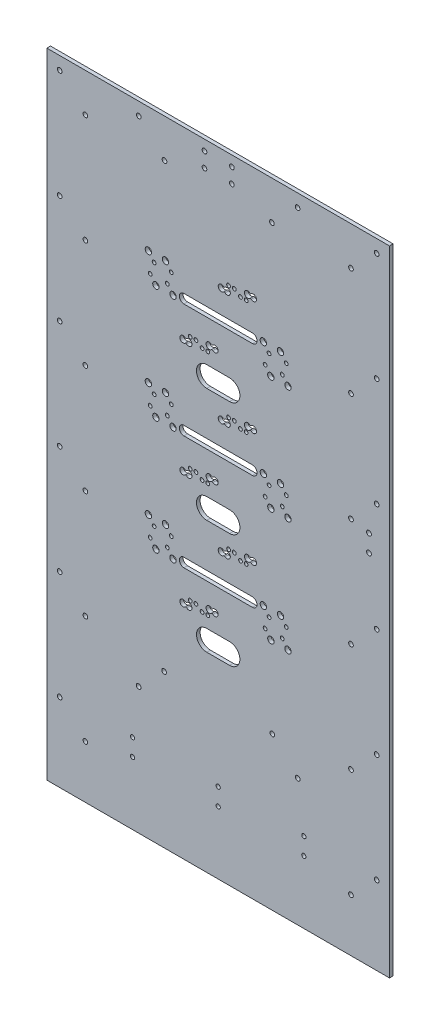
from build123d import *

# Parameters (mm, degrees)
SKETCH1_W           = 300
SKETCH1_H           = 555
BOSS_EXTRUDE1_DEPTH = 3.175
CUT_EXTRUDE1_DEPTH  = 10
SKETCH6_R           = 2.05
CUT_EXTRUDE5_DEPTH  = 51
SKETCH8_R           = 2.1
CUT_EXTRUDE7_DEPTH  = 67
SKETCH9_R           = 2.05
CUT_EXTRUDE8_DEPTH  = 10
SKETCH10_R          = 1.651
SKETCH10_R_2        = 2.794
CUT_EXTRUDE9_DEPTH  = 10
SKETCH12_R          = 1.85
CUT_EXTRUDE10_DEPTH = 10
CUT_EXTRUDE11_DEPTH = 29.1


with BuildPart() as part:
    # Sketch1 → Boss-Extrude1 (new body)
    with BuildSketch(Plane.XY):
        with Locations((-15.986837609, 112.215563673)):
            Rectangle(SKETCH1_W, SKETCH1_H)
    extrude(amount=BOSS_EXTRUDE1_DEPTH)

    # Sketch4 → Cut-Extrude1 (cut)
    with BuildSketch(Plane.XY.offset(3.175)):
        with BuildLine():
            Line((-45.986837609, 263.715563673), (14.013162391, 263.715563673))
            ThreePointArc((14.013162391, 263.715563673), (18.013162391, 259.715563673), (14.013162391, 255.715563673))
            Line((14.013162391, 255.715563673), (-45.986837609, 255.715563673))
            ThreePointArc((-45.986837609, 255.715563673), (-49.986837609, 259.715563673), (-45.986837609, 263.715563673))
        make_face()
        with BuildLine():
            Line((-45.986837609, 163.715563673), (14.013162391, 163.715563673))
            ThreePointArc((14.013162391, 163.715563673), (18.013162391, 159.715563673), (14.013162391, 155.715563673))
            Line((14.013162391, 155.715563673), (-45.986837609, 155.715563673))
            ThreePointArc((-45.986837609, 155.715563673), (-49.986837609, 159.715563673), (-45.986837609, 163.715563673))
        make_face()
        with BuildLine():
            Line((-45.986837609, 63.715563673), (14.013162391, 63.715563673))
            ThreePointArc((14.013162391, 63.715563673), (18.013162391, 59.715563673), (14.013162391, 55.715563673))
            Line((14.013162391, 55.715563673), (-45.986837609, 55.715563673))
            ThreePointArc((-45.986837609, 55.715563673), (-49.986837609, 59.715563673), (-45.986837609, 63.715563673))
        make_face()
    extrude(amount=-CUT_EXTRUDE1_DEPTH, mode=Mode.SUBTRACT)

    # Sketch6 → Cut-Extrude5 (cut)
    with BuildSketch(Plane(origin=(0, 0, 0), x_dir=(-1, 0, 0), z_dir=(0, 0, -1))):
        with Locations((3.986837609, 380.715563673)):
            Circle(SKETCH6_R)
        with Locations((27.986837609, 380.715563673)):
            Circle(SKETCH6_R)
        with Locations((27.986837609, 367.715563673)):
            Circle(SKETCH6_R)
        with Locations((3.986837609, 367.715563673)):
            Circle(SKETCH6_R)
    extrude(amount=-CUT_EXTRUDE5_DEPTH, mode=Mode.SUBTRACT)

    # Sketch8 → Cut-Extrude7 (cut)
    with BuildSketch(Plane(origin=(0, 0, 0), x_dir=(-1, 0, 0), z_dir=(0, 0, -1))):
        with Locations((-116.013162391, 162.980338842)):
            Circle(SKETCH8_R)
        with Locations((-116.013162391, 147.980338842)):
            Circle(SKETCH8_R)
    extrude(amount=-CUT_EXTRUDE7_DEPTH, mode=Mode.SUBTRACT)

    # Sketch9 → Cut-Extrude8 (cut)
    with BuildSketch(Plane(origin=(0, 0, 0), x_dir=(-1, 0, 0), z_dir=(0, 0, -1))):
        with Locations((-122.763162391, 378.465563673)):
            Circle(SKETCH9_R)
        with Locations((-100.263162391, 355.965563673)):
            Circle(SKETCH9_R)
        with Locations((-53.536763897, 378.465563673)):
            Circle(SKETCH9_R)
        with Locations((-31.036763897, 355.965563673)):
            Circle(SKETCH9_R)
        with Locations((-122.763162391, 283.465563673)):
            Circle(SKETCH9_R)
        with Locations((-100.263162391, 260.965563673)):
            Circle(SKETCH9_R)
        with Locations((-122.763162391, 188.465563673)):
            Circle(SKETCH9_R)
        with Locations((-100.263162391, 165.965563673)):
            Circle(SKETCH9_R)
        with Locations((-122.763162391, 93.465563673)):
            Circle(SKETCH9_R)
        with Locations((-100.263162391, 70.965563673)):
            Circle(SKETCH9_R)
        with Locations((-122.763162391, -1.534436327)):
            Circle(SKETCH9_R)
        with Locations((-100.263162391, -24.034436327)):
            Circle(SKETCH9_R)
        with Locations((-122.763162391, -96.534436327)):
            Circle(SKETCH9_R)
        with Locations((-100.263162391, -119.034436327)):
            Circle(SKETCH9_R)
        with Locations((-122.763162391, -191.534436327)):
            Circle(SKETCH9_R)
        with Locations((-100.263162391, -214.034436327)):
            Circle(SKETCH9_R)
        with Locations((-53.648179996, -54.034436327)):
            Circle(SKETCH9_R)
        with Locations((-31.371012194, -31.534436327)):
            Circle(SKETCH9_R)
        with Locations((63.344687413, -31.534436327)):
            Circle(SKETCH9_R)
        with Locations((85.621855215, -54.034436327)):
            Circle(SKETCH9_R)
        with Locations((132.236837609, -214.034436327)):
            Circle(SKETCH9_R)
        with Locations((154.736837609, -191.534436327)):
            Circle(SKETCH9_R)
        with Locations((132.236837609, -119.034436327)):
            Circle(SKETCH9_R)
        with Locations((154.736837609, -96.534436327)):
            Circle(SKETCH9_R)
        with Locations((132.236837609, -24.034436327)):
            Circle(SKETCH9_R)
        with Locations((154.736837609, -1.534436327)):
            Circle(SKETCH9_R)
        with Locations((132.236837609, 70.965563673)):
            Circle(SKETCH9_R)
        with Locations((154.736837609, 93.465563673)):
            Circle(SKETCH9_R)
        with Locations((132.236837609, 165.965563673)):
            Circle(SKETCH9_R)
        with Locations((154.736837609, 188.465563673)):
            Circle(SKETCH9_R)
        with Locations((132.236837609, 260.965563673)):
            Circle(SKETCH9_R)
        with Locations((154.736837609, 283.465563673)):
            Circle(SKETCH9_R)
        with Locations((63.010439116, 355.965563673)):
            Circle(SKETCH9_R)
        with Locations((85.510439116, 378.465563673)):
            Circle(SKETCH9_R)
        with Locations((132.236837609, 355.965563673)):
            Circle(SKETCH9_R)
        with Locations((154.736837609, 378.465563673)):
            Circle(SKETCH9_R)
    extrude(amount=-CUT_EXTRUDE8_DEPTH, mode=Mode.SUBTRACT)

    # Sketch10 → Cut-Extrude9 (cut)
    with BuildSketch(Plane(origin=(0, 0, 0), x_dir=(-1, 0, 0), z_dir=(0, 0, -1))):
        with Locations((35.464045315, 33.621645855)):
            Circle(SKETCH10_R)
        with Locations((25.105079811, 30.160155179)):
            Circle(SKETCH10_R)
        with Locations((-30.126255431, 38.933594969)):
            Circle(SKETCH10_R_2)
        with Locations((-23.543411665, 61.884184155)):
            Circle(SKETCH10_R_2)
        with Locations((-25.10242235, 45.229963762)):
            Circle(SKETCH10_R)
        with Locations((-28.567244746, 55.587815362)):
            Circle(SKETCH10_R)
        with Locations((-45.126255431, 38.933594969)):
            Circle(SKETCH10_R_2)
        with Locations((-38.543411665, 61.884184155)):
            Circle(SKETCH10_R_2)
        with Locations((-40.10242235, 45.229963762)):
            Circle(SKETCH10_R)
        with Locations((-43.567244746, 55.587815362)):
            Circle(SKETCH10_R)
        with Locations((40.464045315, 33.621645855)):
            Circle(SKETCH10_R)
        with Locations((30.105079811, 30.160155179)):
            Circle(SKETCH10_R)
        with Locations((55.517086884, 57.54692847)):
            Circle(SKETCH10_R_2)
        with Locations((70.517086884, 57.54692847)):
            Circle(SKETCH10_R_2)
        with Locations((75.540919965, 63.843297263)):
            Circle(SKETCH10_R)
        with Locations((60.540919965, 63.843297263)):
            Circle(SKETCH10_R)
        with Locations((-3.490370096, 85.80947413)):
            Circle(SKETCH10_R)
        with Locations((6.868595408, 89.270964805)):
            Circle(SKETCH10_R)
        with Locations((62.09993065, 80.497517656)):
            Circle(SKETCH10_R_2)
        with Locations((57.076097569, 74.201148863)):
            Circle(SKETCH10_R)
        with Locations((77.09993065, 80.497517656)):
            Circle(SKETCH10_R_2)
        with Locations((72.076097569, 74.201148863)):
            Circle(SKETCH10_R)
        with Locations((-8.490370096, 85.80947413)):
            Circle(SKETCH10_R)
        with Locations((1.868595408, 89.270964805)):
            Circle(SKETCH10_R)
        with Locations((35.464045315, 133.621645855)):
            Circle(SKETCH10_R)
        with Locations((25.105079811, 130.160155179)):
            Circle(SKETCH10_R)
        with Locations((-30.126255431, 138.933594969)):
            Circle(SKETCH10_R_2)
        with Locations((-23.543411665, 161.884184155)):
            Circle(SKETCH10_R_2)
        with Locations((-25.10242235, 145.229963762)):
            Circle(SKETCH10_R)
        with Locations((-28.567244746, 155.587815362)):
            Circle(SKETCH10_R)
        with Locations((-45.126255431, 138.933594969)):
            Circle(SKETCH10_R_2)
        with Locations((-38.543411665, 161.884184155)):
            Circle(SKETCH10_R_2)
        with Locations((-40.10242235, 145.229963762)):
            Circle(SKETCH10_R)
        with Locations((-43.567244746, 155.587815362)):
            Circle(SKETCH10_R)
        with Locations((40.464045315, 133.621645855)):
            Circle(SKETCH10_R)
        with Locations((30.105079811, 130.160155179)):
            Circle(SKETCH10_R)
        with Locations((55.517086884, 157.54692847)):
            Circle(SKETCH10_R_2)
        with Locations((70.517086884, 157.54692847)):
            Circle(SKETCH10_R_2)
        with Locations((75.540919965, 163.843297263)):
            Circle(SKETCH10_R)
        with Locations((60.540919965, 163.843297263)):
            Circle(SKETCH10_R)
        with Locations((-3.490370096, 185.80947413)):
            Circle(SKETCH10_R)
        with Locations((6.868595408, 189.270964805)):
            Circle(SKETCH10_R)
        with Locations((62.09993065, 180.497517656)):
            Circle(SKETCH10_R_2)
        with Locations((57.076097569, 174.201148863)):
            Circle(SKETCH10_R)
        with Locations((77.09993065, 180.497517656)):
            Circle(SKETCH10_R_2)
        with Locations((72.076097569, 174.201148863)):
            Circle(SKETCH10_R)
        with Locations((-8.490370096, 185.80947413)):
            Circle(SKETCH10_R)
        with Locations((1.868595408, 189.270964805)):
            Circle(SKETCH10_R)
        with Locations((35.464045315, 233.621645855)):
            Circle(SKETCH10_R)
        with Locations((25.105079811, 230.160155179)):
            Circle(SKETCH10_R)
        with Locations((-30.126255431, 238.933594969)):
            Circle(SKETCH10_R_2)
        with Locations((-23.543411665, 261.884184155)):
            Circle(SKETCH10_R_2)
        with Locations((-25.10242235, 245.229963762)):
            Circle(SKETCH10_R)
        with Locations((-28.567244746, 255.587815362)):
            Circle(SKETCH10_R)
        with Locations((-45.126255431, 238.933594969)):
            Circle(SKETCH10_R_2)
        with Locations((-38.543411665, 261.884184155)):
            Circle(SKETCH10_R_2)
        with Locations((-40.10242235, 245.229963762)):
            Circle(SKETCH10_R)
        with Locations((-43.567244746, 255.587815362)):
            Circle(SKETCH10_R)
        with Locations((40.464045315, 233.621645855)):
            Circle(SKETCH10_R)
        with Locations((30.105079811, 230.160155179)):
            Circle(SKETCH10_R)
        with Locations((55.517086884, 257.54692847)):
            Circle(SKETCH10_R_2)
        with Locations((70.517086884, 257.54692847)):
            Circle(SKETCH10_R_2)
        with Locations((75.540919965, 263.843297263)):
            Circle(SKETCH10_R)
        with Locations((60.540919965, 263.843297263)):
            Circle(SKETCH10_R)
        with Locations((-3.490370096, 285.80947413)):
            Circle(SKETCH10_R)
        with Locations((6.868595408, 289.270964805)):
            Circle(SKETCH10_R)
        with Locations((62.09993065, 280.497517656)):
            Circle(SKETCH10_R_2)
        with Locations((57.076097569, 274.201148863)):
            Circle(SKETCH10_R)
        with Locations((77.09993065, 280.497517656)):
            Circle(SKETCH10_R_2)
        with Locations((72.076097569, 274.201148863)):
            Circle(SKETCH10_R)
        with Locations((-8.490370096, 285.80947413)):
            Circle(SKETCH10_R)
        with Locations((1.868595408, 289.270964805)):
            Circle(SKETCH10_R)
        with BuildLine():
            ThreePointArc((43.599862735, 30.697433927), (38.964797896, 28.595787844), (43.599862735, 26.494141761))
            ThreePointArc((43.599862735, 26.494141761), (44.258797896, 26.741942018), (44.917733056, 26.494141761))
            ThreePointArc((44.917733056, 26.494141761), (49.552797895, 28.595787844), (44.917733056, 30.697433927))
            ThreePointArc((44.917733056, 30.697433927), (44.258797896, 30.44963367), (43.599862735, 30.697433927))
        make_face()
        with BuildLine():
            ThreePointArc((20.651392069, 37.287659273), (16.01632723, 35.18601319), (20.651392069, 33.084367108))
            ThreePointArc((20.651392069, 33.084367108), (21.31032723, 33.332167364), (21.969262391, 33.084367108))
            ThreePointArc((21.969262391, 33.084367108), (26.60432723, 35.18601319), (21.969262391, 37.287659273))
            ThreePointArc((21.969262391, 37.287659273), (21.31032723, 37.039859016), (20.651392069, 37.287659273))
        make_face()
        with BuildLine():
            ThreePointArc((-11.626187516, 88.733686058), (-6.991122677, 90.835332141), (-11.626187516, 92.936978224))
            ThreePointArc((-11.626187516, 92.936978224), (-12.285122677, 92.689177967), (-12.944057838, 92.936978224))
            ThreePointArc((-12.944057838, 92.936978224), (-17.579122676, 90.835332141), (-12.944057838, 88.733686058))
            ThreePointArc((-12.944057838, 88.733686058), (-12.285122677, 88.981486315), (-11.626187516, 88.733686058))
        make_face()
        with BuildLine():
            ThreePointArc((11.32228315, 82.143460711), (15.957347989, 84.245106794), (11.32228315, 86.346752877))
            ThreePointArc((11.32228315, 86.346752877), (10.663347989, 86.09895262), (10.004412828, 86.346752877))
            ThreePointArc((10.004412828, 86.346752877), (5.369347989, 84.245106794), (10.004412828, 82.143460711))
            ThreePointArc((10.004412828, 82.143460711), (10.663347989, 82.391260968), (11.32228315, 82.143460711))
        make_face()
        with BuildLine():
            ThreePointArc((43.599862735, 130.697433927), (38.964797896, 128.595787844), (43.599862735, 126.494141761))
            ThreePointArc((43.599862735, 126.494141761), (44.258797896, 126.741942018), (44.917733056, 126.494141761))
            ThreePointArc((44.917733056, 126.494141761), (49.552797895, 128.595787844), (44.917733056, 130.697433927))
            ThreePointArc((44.917733056, 130.697433927), (44.258797896, 130.44963367), (43.599862735, 130.697433927))
        make_face()
        with BuildLine():
            ThreePointArc((20.651392069, 137.287659273), (16.01632723, 135.18601319), (20.651392069, 133.084367108))
            ThreePointArc((20.651392069, 133.084367108), (21.31032723, 133.332167364), (21.969262391, 133.084367108))
            ThreePointArc((21.969262391, 133.084367108), (26.60432723, 135.18601319), (21.969262391, 137.287659273))
            ThreePointArc((21.969262391, 137.287659273), (21.31032723, 137.039859016), (20.651392069, 137.287659273))
        make_face()
        with BuildLine():
            ThreePointArc((-11.626187516, 188.733686058), (-6.991122677, 190.835332141), (-11.626187516, 192.936978224))
            ThreePointArc((-11.626187516, 192.936978224), (-12.285122677, 192.689177967), (-12.944057838, 192.936978224))
            ThreePointArc((-12.944057838, 192.936978224), (-17.579122676, 190.835332141), (-12.944057838, 188.733686058))
            ThreePointArc((-12.944057838, 188.733686058), (-12.285122677, 188.981486315), (-11.626187516, 188.733686058))
        make_face()
        with BuildLine():
            ThreePointArc((11.32228315, 182.143460711), (15.957347989, 184.245106794), (11.32228315, 186.346752877))
            ThreePointArc((11.32228315, 186.346752877), (10.663347989, 186.09895262), (10.004412828, 186.346752877))
            ThreePointArc((10.004412828, 186.346752877), (5.369347989, 184.245106794), (10.004412828, 182.143460711))
            ThreePointArc((10.004412828, 182.143460711), (10.663347989, 182.391260968), (11.32228315, 182.143460711))
        make_face()
        with BuildLine():
            ThreePointArc((43.599862735, 230.697433927), (38.964797896, 228.595787844), (43.599862735, 226.494141761))
            ThreePointArc((43.599862735, 226.494141761), (44.258797896, 226.741942018), (44.917733056, 226.494141761))
            ThreePointArc((44.917733056, 226.494141761), (49.552797895, 228.595787844), (44.917733056, 230.697433927))
            ThreePointArc((44.917733056, 230.697433927), (44.258797896, 230.44963367), (43.599862735, 230.697433927))
        make_face()
        with BuildLine():
            ThreePointArc((20.651392069, 237.287659273), (16.01632723, 235.18601319), (20.651392069, 233.084367108))
            ThreePointArc((20.651392069, 233.084367108), (21.31032723, 233.332167364), (21.969262391, 233.084367108))
            ThreePointArc((21.969262391, 233.084367108), (26.60432723, 235.18601319), (21.969262391, 237.287659273))
            ThreePointArc((21.969262391, 237.287659273), (21.31032723, 237.039859016), (20.651392069, 237.287659273))
        make_face()
        with BuildLine():
            ThreePointArc((-11.626187516, 288.733686058), (-6.991122677, 290.835332141), (-11.626187516, 292.936978224))
            ThreePointArc((-11.626187516, 292.936978224), (-12.285122677, 292.689177967), (-12.944057838, 292.936978224))
            ThreePointArc((-12.944057838, 292.936978224), (-17.579122677, 290.835332141), (-12.944057838, 288.733686058))
            ThreePointArc((-12.944057838, 288.733686058), (-12.285122677, 288.981486315), (-11.626187516, 288.733686058))
        make_face()
        with BuildLine():
            ThreePointArc((11.32228315, 282.143460711), (15.957347989, 284.245106794), (11.32228315, 286.346752877))
            ThreePointArc((11.32228315, 286.346752877), (10.663347989, 286.09895262), (10.004412828, 286.346752877))
            ThreePointArc((10.004412828, 286.346752877), (5.369347989, 284.245106794), (10.004412828, 282.143460711))
            ThreePointArc((10.004412828, 282.143460711), (10.663347989, 282.391260968), (11.32228315, 282.143460711))
        make_face()
    extrude(amount=-CUT_EXTRUDE9_DEPTH, mode=Mode.SUBTRACT)

    # Sketch12 → Cut-Extrude10 (cut)
    with BuildSketch(Plane(origin=(0, 0, 0), x_dir=(-1, 0, 0), z_dir=(0, 0, -1))):
        with Locations((90.986837609, -95.207773245)):
            Circle(SKETCH12_R)
        with Locations((90.986837609, -110.207773245)):
            Circle(SKETCH12_R)
        with Locations((15.986837609, -95.207773245)):
            Circle(SKETCH12_R)
        with Locations((15.986837609, -110.207773245)):
            Circle(SKETCH12_R)
        with Locations((-59.013162391, -95.207773245)):
            Circle(SKETCH12_R)
        with Locations((-59.013162391, -110.207773245)):
            Circle(SKETCH12_R)
    extrude(amount=-CUT_EXTRUDE10_DEPTH, mode=Mode.SUBTRACT)

    # Sketch13 → Cut-Extrude11 (cut)
    with BuildSketch(Plane.XY.offset(3.175)):
        with BuildLine():
            Line((-25.986837609, 19.715563673), (-5.986837609, 19.715563673))
            ThreePointArc((-5.986837609, 19.715563673), (3.013162391, 10.715563673), (-5.986837609, 1.715563673))
            Line((-5.986837609, 1.715563673), (-25.986837609, 1.715563673))
            ThreePointArc((-25.986837609, 1.715563673), (-34.986837609, 10.715563673), (-25.986837609, 19.715563673))
        make_face()
        with BuildLine():
            Line((-25.986837609, 119.715563673), (-5.986837609, 119.715563673))
            ThreePointArc((-5.986837609, 119.715563673), (3.013162391, 110.715563673), (-5.986837609, 101.715563673))
            Line((-5.986837609, 101.715563673), (-25.986837609, 101.715563673))
            ThreePointArc((-25.986837609, 101.715563673), (-34.986837609, 110.715563673), (-25.986837609, 119.715563673))
        make_face()
        with BuildLine():
            Line((-25.986837609, 219.715563673), (-5.986837609, 219.715563673))
            ThreePointArc((-5.986837609, 219.715563673), (3.013162391, 210.715563673), (-5.986837609, 201.715563673))
            Line((-5.986837609, 201.715563673), (-25.986837609, 201.715563673))
            ThreePointArc((-25.986837609, 201.715563673), (-34.986837609, 210.715563673), (-25.986837609, 219.715563673))
        make_face()
    extrude(amount=-CUT_EXTRUDE11_DEPTH, mode=Mode.SUBTRACT)


solid = part.part
